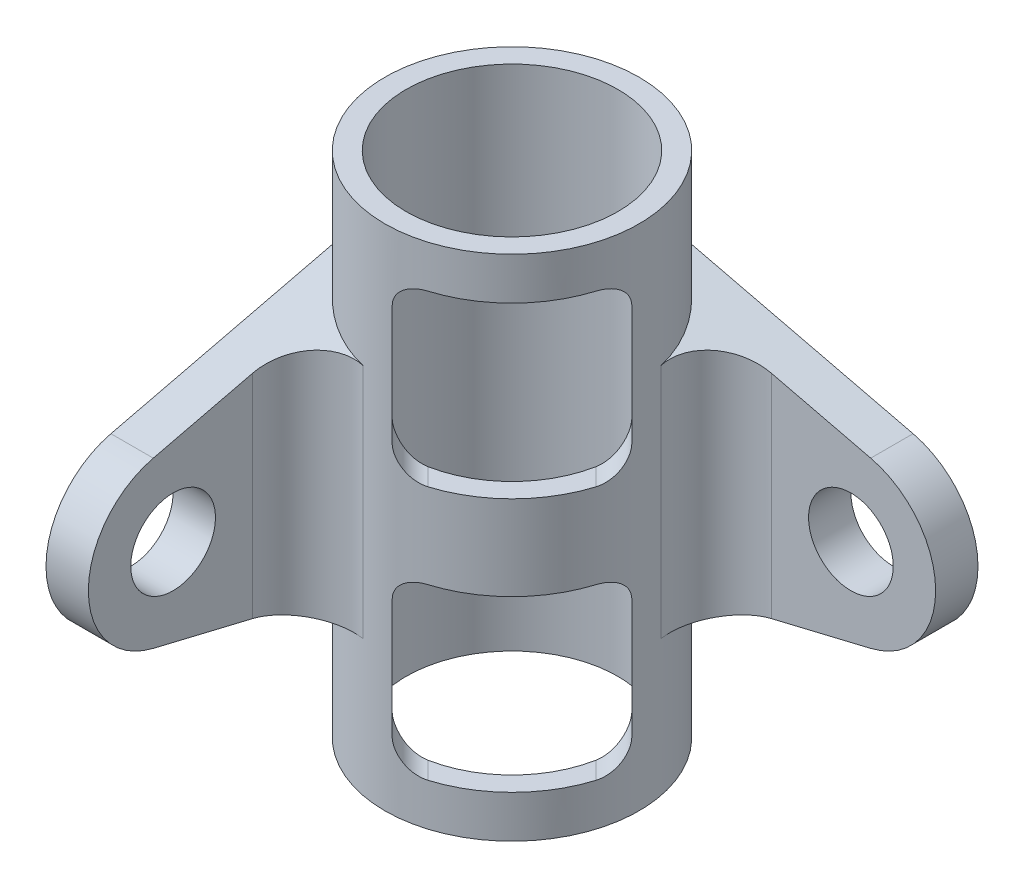
from build123d import *

# Parameters (mm, degrees)
SKETCH_1_R               = 15
EXTRUDE_3_DEPTH          = 30
SKETCH_4_R               = 5
EXTRUDE_4_DEPTH          = 5
SKETCH_5_R               = 5
EXTRUDE_5_DEPTH          = 5
FILLET_1_R               = 6
CUT_EXTRUDE_4_DEPTH      = 65.031242374
CUT_EXTRUDE_4_DEPTH_BACK = 65.031242374
SKETCH_1_3_R             = 12.5
CUT_EXTRUDE_3_REACH      = 53.263
CUT_EXTRUDE_3_END_RADIUS = 12.5


with BuildPart() as part:
    # 草圖1 → 填料-伸長3 (new, symmetric)
    with BuildSketch(Plane(origin=(0, 0, 0), x_dir=(1, 0, 0), z_dir=(0, 1, 0))):
        Circle(SKETCH_1_R)
    extrude(amount=EXTRUDE_3_DEPTH, both=True)

    # 草圖4 → 填料-伸長4 (add)
    with BuildSketch(Plane.ZY.offset(15)):
        with BuildLine():
            Line((0, -17.5), (0, 17.5))
            Line((0, 17.5), (32.338287195, 9.722778049))
            ThreePointArc((32.338287195, 9.722778049), (40, 0), (32.338287195, -9.722778049))
            Line((32.338287195, -9.722778049), (0, -17.5))
        make_face()
        with Locations((30, 0)):
            Circle(SKETCH_4_R, mode=Mode.SUBTRACT)
    extrude(amount=-EXTRUDE_4_DEPTH)

    # 草圖5 → 填料-伸長5 (add)
    with BuildSketch(Plane(origin=(0, 0, -15), x_dir=(-1, 0, 0), z_dir=(0, 0, -1))):
        with BuildLine():
            Line((0, -17.5), (0, 17.5))
            Line((0, 17.5), (-32.338287195, 9.722778049))
            ThreePointArc((-32.338287195, 9.722778049), (-40, 0), (-32.338287195, -9.722778049))
            Line((-32.338287195, -9.722778049), (0, -17.5))
        make_face()
        with Locations((-30, 0)):
            Circle(SKETCH_5_R, mode=Mode.SUBTRACT)
    extrude(amount=-EXTRUDE_5_DEPTH)

    # 圓角1
    fillet_1_edges = [part.edges().sort_by_distance(p)[0] for p in [
        (11.180339887, 0, -10),
        (-10, 0, 11.180339887),
    ]]
    fillet(fillet_1_edges, radius=FILLET_1_R)

    # 草圖1<3> → 除料-伸長4 (cut, two sides: drawn at the far end of the back side and taken through both)
    with BuildSketch(Plane(origin=(0, 0, 0), x_dir=(1, 0, 0), z_dir=(0, 1, 0)).offset(-CUT_EXTRUDE_4_DEPTH_BACK)):
        Circle(SKETCH_1_3_R)
    extrude(amount=CUT_EXTRUDE_4_DEPTH + CUT_EXTRUDE_4_DEPTH_BACK, mode=Mode.SUBTRACT)

    # 除料-伸長3: up to this cylinder (the profile starts outside it)
    cut_extrude_3_end = Plane(origin=(0, 0, 0), z_dir=(0, 1, 0)) * Cylinder(CUT_EXTRUDE_3_END_RADIUS, 162.526, mode=Mode.PRIVATE)
    # 草圖7 → 除料-伸長3 (cut, up to the surface)
    with BuildSketch(Plane(origin=(10.606601718, 0, 10.606601718), x_dir=(0.7071067811865487, 0, -0.7071067811865465), z_dir=(0.7071067811865465, 0, 0.7071067811865487)), mode=Mode.PRIVATE) as cut_extrude_3_sk1:
        with BuildLine():
            Line((-7, 25), (7, 25))
            ThreePointArc((7, 25), (9.121320344, 24.121320344), (10, 22))
            Line((10, 22), (10, 8))
            ThreePointArc((10, 8), (9.121320344, 5.878679656), (7, 5))
            Line((7, 5), (-7, 5))
            ThreePointArc((-7, 5), (-9.121320344, 5.878679656), (-10, 8))
            Line((-10, 8), (-10, 22))
            ThreePointArc((-10, 22), (-9.121320344, 24.121320344), (-7, 25))
        make_face()
    cut_extrude_3_tool1 = extrude(cut_extrude_3_sk1.sketch, amount=-CUT_EXTRUDE_3_REACH, mode=Mode.PRIVATE) - cut_extrude_3_end
    add(cut_extrude_3_tool1.solids().sort_by_distance((10.606602, 15, 10.606602))[0], mode=Mode.SUBTRACT)
    # 草圖7 → 除料-伸長3 (cut, up to the surface)
    with BuildSketch(Plane(origin=(10.606601718, 0, 10.606601718), x_dir=(0.7071067811865487, 0, -0.7071067811865465), z_dir=(0.7071067811865465, 0, 0.7071067811865487)), mode=Mode.PRIVATE) as cut_extrude_3_sk2:
        with BuildLine():
            Line((-7, -5), (7, -5))
            ThreePointArc((7, -5), (9.121320344, -5.878679656), (10, -8))
            Line((10, -8), (10, -22))
            ThreePointArc((10, -22), (9.121320344, -24.121320344), (7, -25))
            Line((7, -25), (-7, -25))
            ThreePointArc((-7, -25), (-9.121320344, -24.121320344), (-10, -22))
            Line((-10, -22), (-10, -8))
            ThreePointArc((-10, -8), (-9.121320344, -5.878679656), (-7, -5))
        make_face()
    cut_extrude_3_tool2 = extrude(cut_extrude_3_sk2.sketch, amount=-CUT_EXTRUDE_3_REACH, mode=Mode.PRIVATE) - cut_extrude_3_end
    add(cut_extrude_3_tool2.solids().sort_by_distance((10.606602, -15, 10.606602))[0], mode=Mode.SUBTRACT)


solid = part.part
